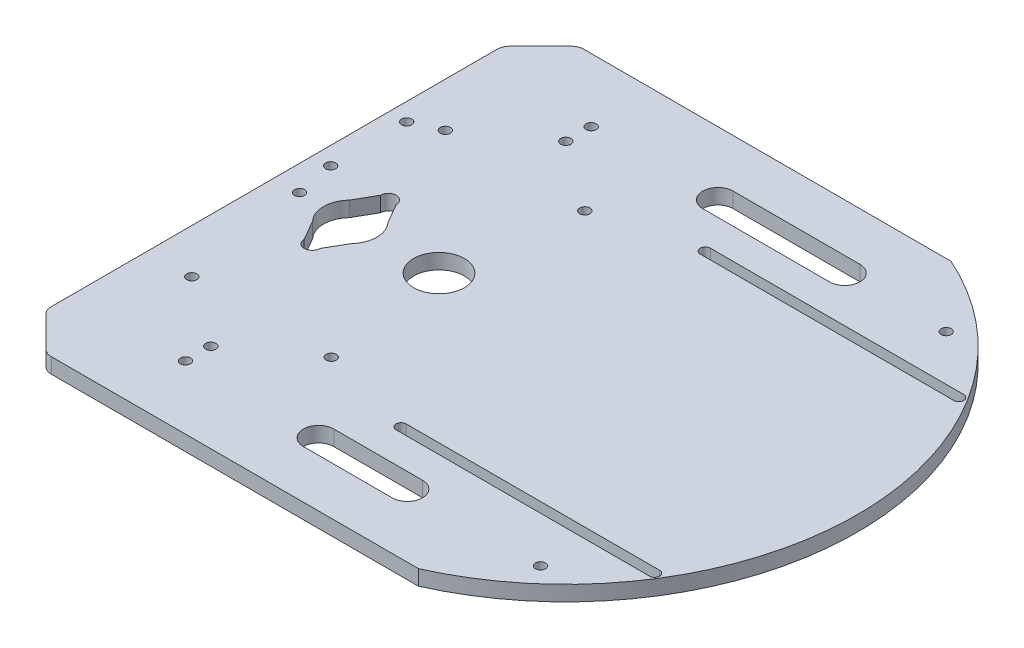
from build123d import *

# Parameters (mm, degrees)
SKETCH1_R           = 2
SKETCH1_R_2         = 10.5
BOSS_EXTRUDE1_DEPTH = 6
SKETCH2_R           = 10
SKETCH2_R_2         = 2
CUT_EXTRUDE2_DEPTH  = 19
BOSS_EXTRUDE2_DEPTH = 6
CHAMFER1_SIZE       = 15
FILLET1_R           = 5
SKETCH4_R           = 2
CUT_EXTRUDE3_DEPTH  = 10
CUT_EXTRUDE4_DEPTH  = 10


with BuildPart() as part:
    # Sketch1 → Boss-Extrude1 (new body)
    with BuildSketch(Plane(origin=(0, 0, 0), x_dir=(1, 0, 0), z_dir=(0, 1, 0))):
        with BuildLine():
            Line((-46.904157598, -105), (46.904157598, -105))
            ThreePointArc((46.904157598, -105), (115, 0), (46.904157598, 105))
            Line((46.904157598, 105), (-46.904157598, 105))
            ThreePointArc((-46.904157598, 105), (-115, 0), (-46.904157598, -105))
        make_face()
        with Locations((-70, 80)):
            Circle(SKETCH1_R, mode=Mode.SUBTRACT)
        with Locations((70, 80)):
            Circle(SKETCH1_R, mode=Mode.SUBTRACT)
        with Locations((70, -80)):
            Circle(SKETCH1_R, mode=Mode.SUBTRACT)
        with Locations((-70, -80)):
            Circle(SKETCH1_R, mode=Mode.SUBTRACT)
        with Locations((-85, 0)):
            Circle(SKETCH1_R_2, mode=Mode.SUBTRACT)
    extrude(amount=BOSS_EXTRUDE1_DEPTH)

    # Sketch2 → Cut-Extrude2 (cut)
    with BuildSketch(Plane.XZ):
        with Locations((-50, 0)):
            Circle(SKETCH2_R)
        with Locations((-105, 0)):
            Circle(SKETCH2_R_2)
        with BuildLine():
            Line((-88.153729078, 15), (-92.680195826, 7.159929613))
            ThreePointArc((-92.680195826, 7.159929613), (-95.5, 0), (-92.680195826, -7.159929613))
            Line((-92.680195826, -7.159929613), (-88.153729078, -15))
            ThreePointArc((-88.153729078, -15), (-85, -18.153729078), (-81.846270922, -15))
            Line((-81.846270922, -15), (-77.319804174, -7.159929613))
            ThreePointArc((-77.319804174, -7.159929613), (-74.5, 0), (-77.319804174, 7.159929613))
            Line((-77.319804174, 7.159929613), (-81.846270922, 15))
            ThreePointArc((-81.846270922, 15), (-85, 18.153729078), (-88.153729078, 15))
        make_face()
        with BuildLine():
            Line((-20, -74), (30, -74))
            ThreePointArc((30, -74), (36, -80), (30, -86))
            Line((30, -86), (-20, -86))
            ThreePointArc((-20, -86), (-26, -80), (-20, -74))
        make_face()
        with BuildLine():
            Line((17.5, 74), (-17.5, 74))
            ThreePointArc((-17.5, 74), (-23.5, 80), (-17.5, 86))
            Line((-17.5, 86), (17.5, 86))
            ThreePointArc((17.5, 86), (23.5, 80), (17.5, 74))
        make_face()
    extrude(amount=-CUT_EXTRUDE2_DEPTH, mode=Mode.SUBTRACT)

    # Sketch3 → Boss-Extrude2 (add)
    with BuildSketch(Plane(origin=(0, 0, 0), x_dir=(-1, 0, 0), z_dir=(0, -1, 0))):
        with BuildLine():
            ThreePointArc((115, 0), (96.485693561, -62.574043645), (46.904157598, -105))
            Line((46.904157598, -105), (115, -105))
            Line((115, -105), (115, 0))
        make_face()
        with BuildLine():
            ThreePointArc((46.904157598, 105), (96.485693561, 62.574043645), (115, 0))
            Line((115, 0), (115, 105))
            Line((115, 105), (46.904157598, 105))
        make_face()
    extrude(amount=-BOSS_EXTRUDE2_DEPTH)

    # Chamfer1
    chamfer1_edges = [part.edges().sort_by_distance(p)[0] for p in [
        (-115, 3, 105),
        (-115, 3, -105),
    ]]
    chamfer(chamfer1_edges, length=CHAMFER1_SIZE)

    # Fillet1
    fillet1_edges = [part.edges().sort_by_distance(p)[0] for p in [
        (-115, 3, 90),
        (-115, 3, -90),
        (-100, 3, -105),
        (-100, 3, 105),
    ]]
    fillet(fillet1_edges, radius=FILLET1_R)

    # Sketch4 → Cut-Extrude3 (cut)
    with BuildSketch(Plane(origin=(0, 6, 0), x_dir=(1, 0, 0), z_dir=(0, 1, 0))):
        with Locations((-42.5, -50)):
            Circle(SKETCH4_R)
        with Locations((-97.5, -50)):
            Circle(SKETCH4_R)
        with Locations((-97.5, 50)):
            Circle(SKETCH4_R)
        with Locations((-42.5, 50)):
            Circle(SKETCH4_R)
        with Locations((-70, 70)):
            Circle(SKETCH4_R)
        with Locations((-70, -70)):
            Circle(SKETCH4_R)
        with Locations((-108, 15.259313515)):
            Circle(SKETCH4_R)
        with Locations((-108, 45.259313515)):
            Circle(SKETCH4_R)
    extrude(amount=-CUT_EXTRUDE3_DEPTH, mode=Mode.SUBTRACT)

    # Sketch5 → Cut-Extrude4 (cut)
    with BuildSketch(Plane(origin=(0, 6, 0), x_dir=(1, 0, 0), z_dir=(0, 1, 0))):
        with BuildLine():
            Line((-5, 62), (95, 62))
            ThreePointArc((95, 62), (97, 60), (95, 58))
            Line((95, 58), (-5, 58))
            ThreePointArc((-5, 58), (-7, 60), (-5, 62))
        make_face()
        with BuildLine():
            Line((-5, -62), (95, -62))
            ThreePointArc((95, -62), (97, -60), (95, -58))
            Line((95, -58), (-5, -58))
            ThreePointArc((-5, -58), (-7, -60), (-5, -62))
        make_face()
    extrude(amount=-CUT_EXTRUDE4_DEPTH, mode=Mode.SUBTRACT)


solid = part.part
